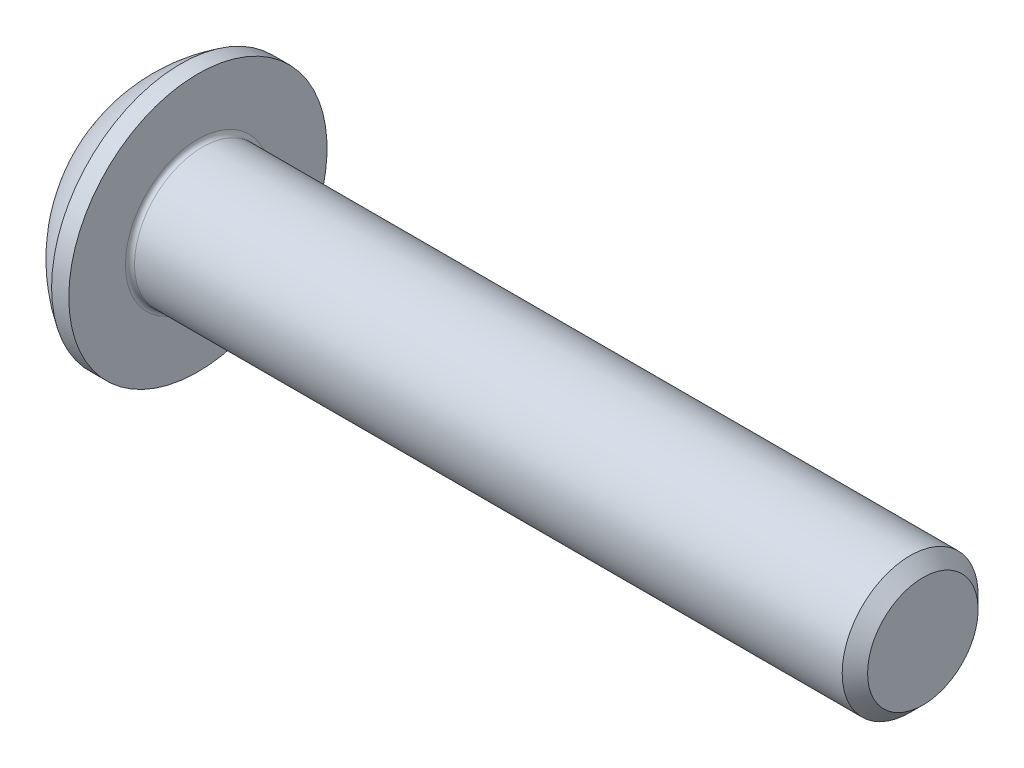
from build123d import *

# Parameters (mm, degrees)
FILLET1_R   = 0.1
HEX_2_DEPTH = 1.04


with BuildPart() as part:
    # BodySke → BaseBody (revolve)
    with BuildSketch(Plane.XY):
        with BuildLine():
            Line((17.65, 0), (17.65, 1.2195))
            Line((17.65, 1.2195), (17.3695, 1.5))
            Line((17.3695, 1.5), (1.65, 1.5))
            Line((1.65, 1.5), (1.65, 2.85))
            Line((1.65, 2.85), (1.27, 2.85))
            ThreePointArc((1.27, 2.85), (0.53140404, 2.229827628), (0, 1.425))
            Line((0, 1.425), (0, 0))
            Line((0, 0), (17.65, 0))
        make_face()
    revolve(axis=Axis((0, 0, 0), (1, 0, 0)))

    # Fillet1
    fillet1_edges = [part.edges().sort_by_distance(p)[0] for p in [
        (1.65, -1.5, 0),
    ]]
    fillet(fillet1_edges, radius=FILLET1_R)

    # Sketch2 → PreBroach (revolve, cut)
    with BuildSketch(Plane.XY):
        Polygon((0, 1), (1.04, 1), (1.617350269, 0), (0, 0), align=None)
    revolve(axis=Axis((0, 0, 0), (1, 0, 0)), mode=Mode.SUBTRACT)

    # Sketch3 → Hex 2 (cut)
    with BuildSketch(Plane(origin=(0, 0, 0), x_dir=(0, 0, -1), z_dir=(1, 0, 0))):
        Polygon((-1, -0.577350269), (-1, 0.577350269), (0, 1.154700538), (1, 0.577350269), (1, -0.577350269), (0, -1.154700538), align=None)
    extrude(amount=HEX_2_DEPTH, mode=Mode.SUBTRACT)


solid = part.part
